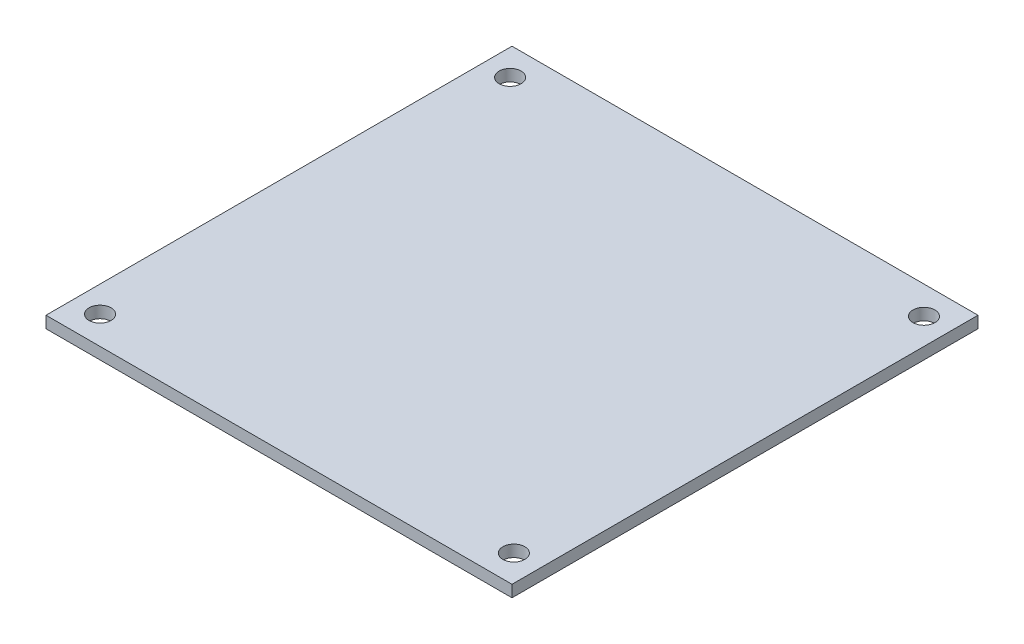
from build123d import *

# Parameters (mm, degrees)
SKETCH1_W           = 63.5
SKETCH1_H           = 63.5
SKETCH1_R           = 1.5
BOSS_EXTRUDE1_DEPTH = 1.6


with BuildPart() as part:
    # Sketch1 → Boss-Extrude1 (new body)
    with BuildSketch(Plane(origin=(0, 0, 0), x_dir=(1, 0, 0), z_dir=(0, 1, 0))):
        Rectangle(SKETCH1_W, SKETCH1_H)
        with Locations((-28.194, 27.94)):
            Circle(SKETCH1_R, mode=Mode.SUBTRACT)
        with Locations((28.194, 27.94)):
            Circle(SKETCH1_R, mode=Mode.SUBTRACT)
        with Locations((28.194, -27.94)):
            Circle(SKETCH1_R, mode=Mode.SUBTRACT)
        with Locations((-28.194, -27.94)):
            Circle(SKETCH1_R, mode=Mode.SUBTRACT)
    extrude(amount=BOSS_EXTRUDE1_DEPTH)


solid = part.part
